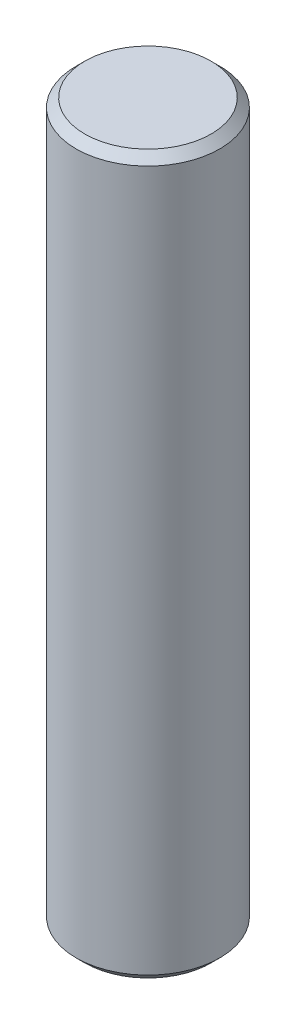
from build123d import *

# Parameters (mm, degrees)
SKETCH1_R           = 6.35
BOSS_EXTRUDE1_DEPTH = 63.5
CHAMFER1_SIZE       = 0.762


with BuildPart() as part:
    # Sketch1 → Boss-Extrude1 (new body)
    with BuildSketch(Plane(origin=(0, 0, 0), x_dir=(1, 0, 0), z_dir=(0, 1, 0))):
        Circle(SKETCH1_R)
    extrude(amount=BOSS_EXTRUDE1_DEPTH)

    # Chamfer1
    chamfer1_edges = [part.edges().sort_by_distance(p)[0] for p in [
        (-6.35, 0, 0),
        (-6.35, 63.5, 0),
    ]]
    chamfer(chamfer1_edges, length=CHAMFER1_SIZE)


solid = part.part
